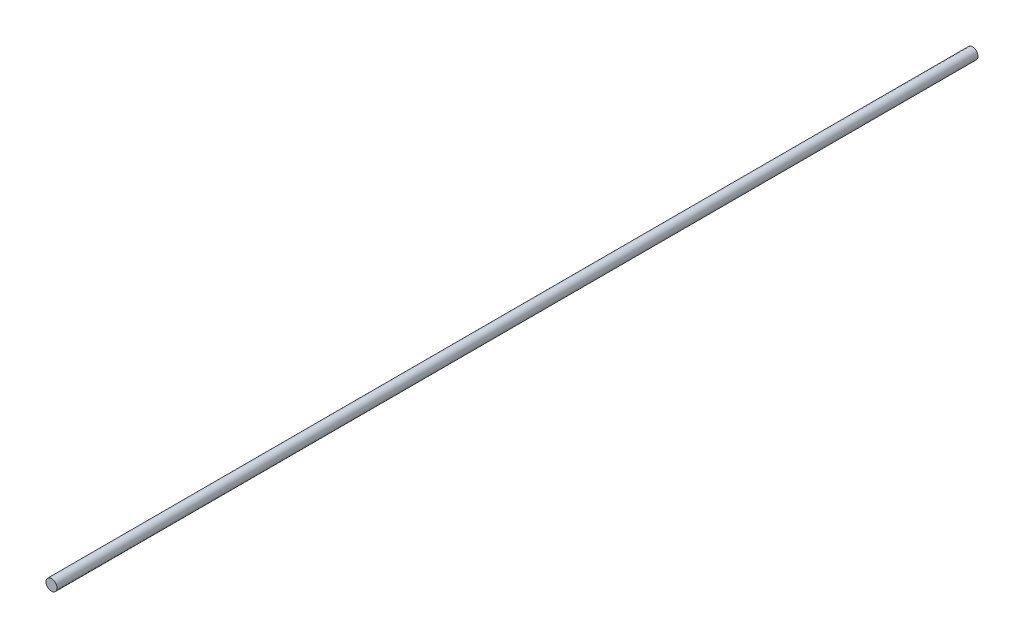
from build123d import *

# Parameters (mm, degrees)
SKETCH1_R           = 3.175
BOSS_EXTRUDE1_DEPTH = 532.435


with BuildPart() as part:
    # Sketch1 → Boss-Extrude1 (new body)
    with BuildSketch(Plane.XY):
        Circle(SKETCH1_R)
    extrude(amount=BOSS_EXTRUDE1_DEPTH)


solid = part.part
